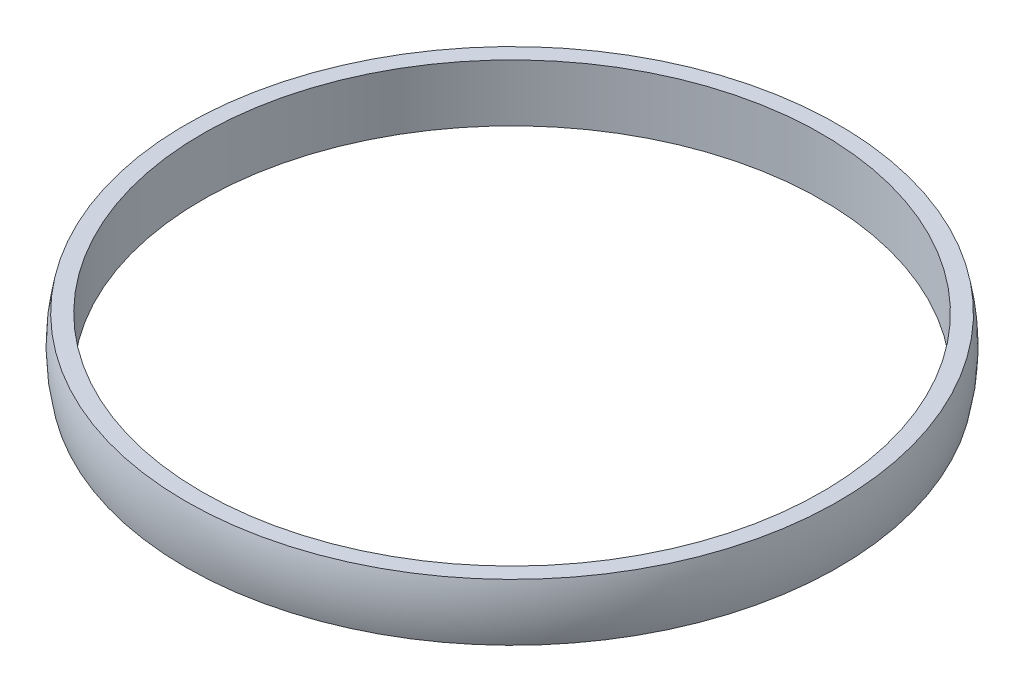
from build123d import *


with BuildPart() as part:
    # Sketch1 → Revolve1 (revolve)
    with BuildSketch(Plane.XY):
        with BuildLine():
            Line((38, 3.5), (40, 3.5))
            ThreePointArc((40, 3.5), (40.402921801, 0), (40, -3.5))
            Line((40, -3.5), (38, -3.5))
            Line((38, -3.5), (38, 3.5))
        make_face()
    revolve(axis=Axis((0, 2.681291581, 0), (0, -1, 0)))


solid = part.part
